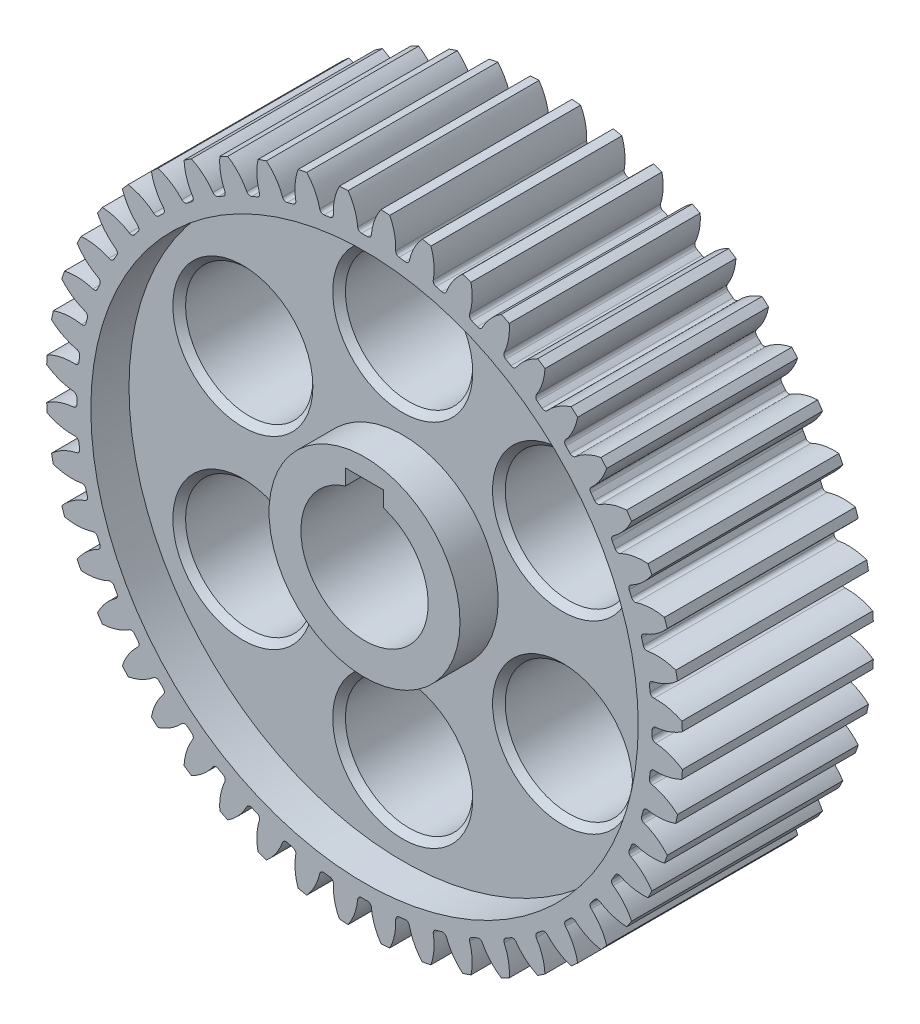
from build123d import *

# Parameters (mm, degrees)
SKBASE_R                                 = 25
BASE_DEPTH                               = 7.5
TOOTHPROFILE_DEPTH                       = 8.5
FILLETTOOTHPROFILE_R                     = 0.3
CIRPATTERNTEETH_COUNT                    = 48
FILLETTOOTHPROFILE_OF_CIRPATTERNTEETH_R  = 0.3
SKCHAVETA_R                              = 5
SKCHAVETA_W                              = 3
SKCHAVETA_H                              = 3
CHAVETA_DEPTH                            = 16.0000001
SKREBAIXO_R                              = 21.5
SKREBAIXO_R_2                            = 7.5
REBAIXO_DEPTH                            = 3
SKBALANCEAMENTO_R                        = 5
BALANCEAMENTO_DEPTH                      = 13.0000001
CHAMFERBALANCEAMENTO_SIZE                = 0.5
CIRPATTERN1_COUNT                        = 6
CHAMFERBALANCEAMENTO_OF_CIRPATTERN1_SIZE = 0.5


with BuildPart() as part:
    # skBase → Base (new body, symmetric)
    with BuildSketch(Plane.XY):
        Circle(SKBASE_R)
    extrude(amount=BASE_DEPTH, both=True)

    # skToothProfile → ToothProfile (cut, symmetric)
    with BuildSketch(Plane.XY):
        with BuildLine():
            ThreePointArc((-0.522942994, 22.593948983), (-0.976916793, 24.434481), (-2.167731859, 25.909475845))
            ThreePointArc((-2.167731859, 25.909475845), (0, 26), (2.167731859, 25.909475845))
            ThreePointArc((2.167731859, 25.909475845), (0.976916793, 24.434481), (0.522942994, 22.593948983))
            ThreePointArc((0.522942994, 22.593948983), (0, 22.6), (-0.522942994, 22.593948983))
        make_face()
    toothprofile = extrude(amount=TOOTHPROFILE_DEPTH, both=True, mode=Mode.SUBTRACT)

    # FilletToothProfile
    fillettoothprofile_edges = [part.edges().sort_by_distance(p)[0] for p in [
        (-0.522942994, 22.593948983, 0),
        (0.522942994, 22.593948983, 0),
    ]]
    fillet(fillettoothprofile_edges, radius=FILLETTOOTHPROFILE_R)

    # CirPatternTeeth: ToothProfile ×48 about axis
    cirpatternteeth_axis = Axis((0, 0, 0), (0, 0, 1))
    for i in range(1, CIRPATTERNTEETH_COUNT):
        add(toothprofile.rotate(cirpatternteeth_axis, i * 360 / CIRPATTERNTEETH_COUNT), mode=Mode.SUBTRACT)

    # FilletToothProfile of CirPatternTeeth
    fillettoothprofile_of_cirpatternteeth_edges = [part.edges().sort_by_distance(p)[0] for p in [
        (-3.467571272, 22.332396859, 0),
        (-2.430632984, 22.468912375, 0),
        (-6.352868444, 21.688731234, 0),
        (-5.342620157, 21.959426446, 0),
        (-9.129466276, 20.673965404, 0),
        (-8.163193619, 21.074208643, 0),
        (-11.749856409, 19.305462294, 0),
        (-10.844092574, 19.828405288, 0),
        (-14.169203241, 17.606637371, 0),
        (-13.339446099, 18.24333242, 0),
        (-16.346111076, 15.606558002, 0),
        (-15.606558002, 16.346111076, 0),
        (-18.24333242, 13.339446099, 0),
        (-17.606637371, 14.169203241, 0),
        (-19.828405288, 10.844092574, 0),
        (-19.305462294, 11.749856409, 0),
        (-21.074208643, 8.163193619, 0),
        (-20.673965404, 9.129466276, 0),
        (-21.959426446, 5.342620157, 0),
        (-21.688731234, 6.352868444, 0),
        (-22.468912375, 2.430632984, 0),
        (-22.332396859, 3.467571272, 0),
        (-22.593948983, -0.522942994, 0),
        (-22.593948983, 0.522942994, 0),
        (-22.332396859, -3.467571272, 0),
        (-22.468912375, -2.430632984, 0),
        (-21.688731234, -6.352868444, 0),
        (-21.959426446, -5.342620157, 0),
        (-20.673965404, -9.129466276, 0),
        (-21.074208643, -8.163193619, 0),
        (-19.305462294, -11.749856409, 0),
        (-19.828405288, -10.844092574, 0),
        (-17.606637371, -14.169203241, 0),
        (-18.24333242, -13.339446099, 0),
        (-15.606558002, -16.346111076, 0),
        (-16.346111076, -15.606558002, 0),
        (-13.339446099, -18.24333242, 0),
        (-14.169203241, -17.606637371, 0),
        (-10.844092574, -19.828405288, 0),
        (-11.749856409, -19.305462294, 0),
        (-8.163193619, -21.074208643, 0),
        (-9.129466276, -20.673965404, 0),
        (-5.342620157, -21.959426446, 0),
        (-6.352868444, -21.688731234, 0),
        (-2.430632984, -22.468912375, 0),
        (-3.467571272, -22.332396859, 0),
        (0.522942994, -22.593948983, 0),
        (-0.522942994, -22.593948983, 0),
        (3.467571272, -22.332396859, 0),
        (2.430632984, -22.468912375, 0),
        (6.352868444, -21.688731234, 0),
        (5.342620157, -21.959426446, 0),
        (9.129466276, -20.673965404, 0),
        (8.163193619, -21.074208643, 0),
        (11.749856409, -19.305462294, 0),
        (10.844092574, -19.828405288, 0),
        (14.169203241, -17.606637371, 0),
        (13.339446099, -18.24333242, 0),
        (16.346111076, -15.606558002, 0),
        (15.606558002, -16.346111076, 0),
        (18.24333242, -13.339446099, 0),
        (17.606637371, -14.169203241, 0),
        (19.828405288, -10.844092574, 0),
        (19.305462294, -11.749856409, 0),
        (21.074208643, -8.163193619, 0),
        (20.673965404, -9.129466276, 0),
        (21.959426446, -5.342620157, 0),
        (21.688731234, -6.352868444, 0),
        (22.468912375, -2.430632984, 0),
        (22.332396859, -3.467571272, 0),
        (22.593948983, 0.522942994, 0),
        (22.593948983, -0.522942994, 0),
        (22.332396859, 3.467571272, 0),
        (22.468912375, 2.430632984, 0),
        (21.688731234, 6.352868444, 0),
        (21.959426446, 5.342620157, 0),
        (20.673965404, 9.129466276, 0),
        (21.074208643, 8.163193619, 0),
        (19.305462294, 11.749856409, 0),
        (19.828405288, 10.844092574, 0),
        (17.606637371, 14.169203241, 0),
        (18.24333242, 13.339446099, 0),
        (15.606558002, 16.346111076, 0),
        (16.346111076, 15.606558002, 0),
        (13.339446099, 18.24333242, 0),
        (14.169203241, 17.606637371, 0),
        (10.844092574, 19.828405288, 0),
        (11.749856409, 19.305462294, 0),
        (8.163193619, 21.074208643, 0),
        (9.129466276, 20.673965404, 0),
        (5.342620157, 21.959426446, 0),
        (6.352868444, 21.688731234, 0),
        (2.430632984, 22.468912375, 0),
        (3.467571272, 22.332396859, 0),
    ]]
    fillet(fillettoothprofile_of_cirpatternteeth_edges, radius=FILLETTOOTHPROFILE_OF_CIRPATTERNTEETH_R)

    # skChaveta → Chaveta (cut, through all)
    with BuildSketch(Plane.XY.offset(7.5)):
        Circle(SKCHAVETA_R)
        with Locations((0, 4.5)):
            Rectangle(SKCHAVETA_W, SKCHAVETA_H)
    extrude(amount=-CHAVETA_DEPTH, mode=Mode.SUBTRACT)

    # skRebaixo → Rebaixo (cut)
    with BuildSketch(Plane.XY.offset(7.5)):
        Circle(SKREBAIXO_R)
        Circle(SKREBAIXO_R_2, mode=Mode.SUBTRACT)
    rebaixo = extrude(amount=-REBAIXO_DEPTH, mode=Mode.SUBTRACT)

    # MirrorRebaixo: Rebaixo across plane
    add(rebaixo.mirror(Plane.XY), mode=Mode.SUBTRACT)

    # skBalanceamento → Balanceamento (cut, through all)
    with BuildSketch(Plane(origin=(0, 0, -4.5), x_dir=(-1, 0, 0), z_dir=(0, 0, -1))):
        with Locations((0, 14.5)):
            Circle(SKBALANCEAMENTO_R)
    balanceamento = extrude(amount=-BALANCEAMENTO_DEPTH, mode=Mode.SUBTRACT)

    # ChamferBalanceamento
    chamferbalanceamento_edges = [part.edges().sort_by_distance(p)[0] for p in [
        (5, 14.5, 4.5),
        (5, 14.5, -4.5),
    ]]
    chamfer(chamferbalanceamento_edges, length=CHAMFERBALANCEAMENTO_SIZE)

    # CirPattern1: Balanceamento ×6 about axis
    cirpattern1_axis = Axis((0, 0, 0), (0, 0, 1))
    for i in range(1, CIRPATTERN1_COUNT):
        add(balanceamento.rotate(cirpattern1_axis, i * 360 / CIRPATTERN1_COUNT), mode=Mode.SUBTRACT)

    # ChamferBalanceamento of CirPattern1
    chamferbalanceamento_of_cirpattern1_edges = [part.edges().sort_by_distance(p)[0] for p in [
        (-10.057368355, 11.580127019, 4.5),
        (-10.057368355, 11.580127019, -4.5),
        (-15.057368355, -2.919872981, 4.5),
        (-15.057368355, -2.919872981, -4.5),
        (-5, -14.5, 4.5),
        (-5, -14.5, -4.5),
        (10.057368355, -11.580127019, 4.5),
        (10.057368355, -11.580127019, -4.5),
        (15.057368355, 2.919872981, 4.5),
        (15.057368355, 2.919872981, -4.5),
    ]]
    chamfer(chamferbalanceamento_of_cirpattern1_edges, length=CHAMFERBALANCEAMENTO_OF_CIRPATTERN1_SIZE)


solid = part.part
